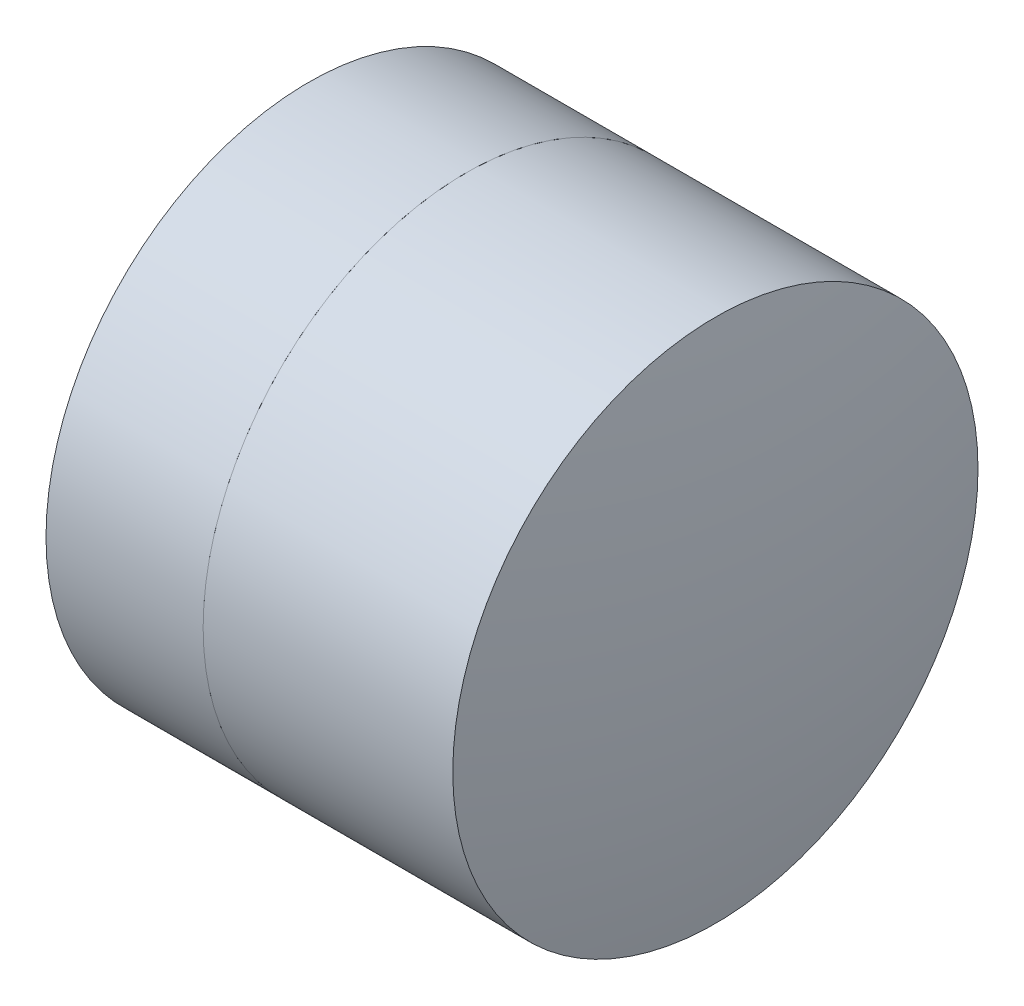
from build123d import *


with BuildPart() as part:
    # 草图1 one side → 旋转1 (revolve)
    with BuildSketch(Plane(origin=(0, 0, 0), x_dir=(1, 0, 0), z_dir=(0, 1, 0)), mode=Mode.PRIVATE) as revolve_1_sk:
        with BuildLine():
            ThreePointArc((0.359060083, 1.5), (0.035852501, 0.780740639), (-0.074787565, 0))
            Line((-0.074787565, 0), (2.025212435, 0))
            ThreePointArc((2.025212435, 0), (1.821875758, 0.84272567), (1.256612268, 1.5))
            Line((1.256612268, 1.5), (0.359060083, 1.5))
        make_face()
    revolve(revolve_1_sk.sketch.rotate(Axis((-0.816062176, 0, 0), (1, 0, 0)), 180), axis=Axis((-0.816062176, 0, 0), (1, 0, 0)))  # turned: the seam where the file's is


with BuildPart() as body_2:
    # 草图2 one side → 旋转2 (revolve)
    with BuildSketch(Plane(origin=(0, 0, 0), x_dir=(1, 0, 0), z_dir=(0, 1, 0)), mode=Mode.PRIVATE) as revolve_2_sk:
        with BuildLine():
            Line((2.682603304, 1.5), (1.256612268, 1.5))
            ThreePointArc((1.256612268, 1.5), (1.821875758, 0.84272567), (2.025212435, 0))
            Line((2.025212435, 0), (2.825212435, 0))
            ThreePointArc((2.825212435, 0), (2.789479951, 0.753381936), (2.682603304, 1.5))
        make_face()
    revolve(revolve_2_sk.sketch.rotate(Axis((-0.551919993, 0, 0), (1, 0, 0)), 180), axis=Axis((-0.551919993, 0, 0), (1, 0, 0)))  # turned: the seam where the file's is


solid = Compound([part.part, body_2.part])
